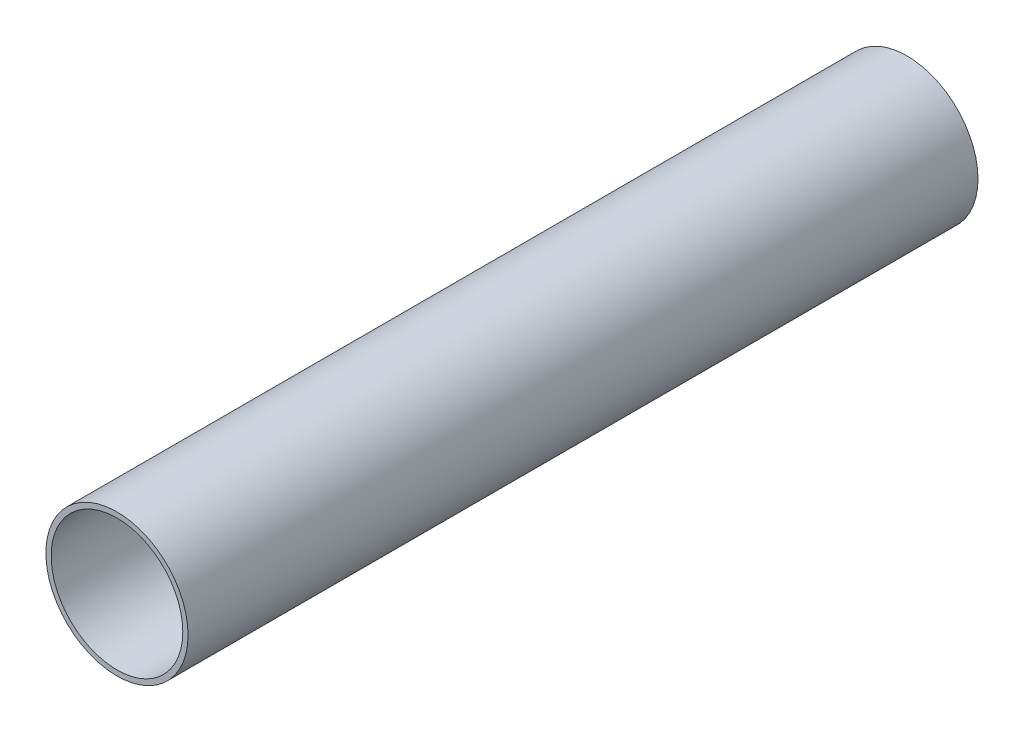
from build123d import *

# Parameters (mm, degrees)
SKETCH1_R           = 27.432
BOSS_EXTRUDE1_DEPTH = 152.4
SKETCH2_R           = 25.4
CUT_EXTRUDE1_DEPTH  = 305.8


with BuildPart() as part:
    # Sketch1 → Boss-Extrude1 (new body, symmetric)
    with BuildSketch(Plane.XY):
        Circle(SKETCH1_R)
    extrude(amount=BOSS_EXTRUDE1_DEPTH, both=True)

    # Sketch2 → Cut-Extrude1 (cut, through all)
    with BuildSketch(Plane.XY.offset(152.4)):
        Circle(SKETCH2_R)
    extrude(amount=-CUT_EXTRUDE1_DEPTH, mode=Mode.SUBTRACT)


solid = part.part
